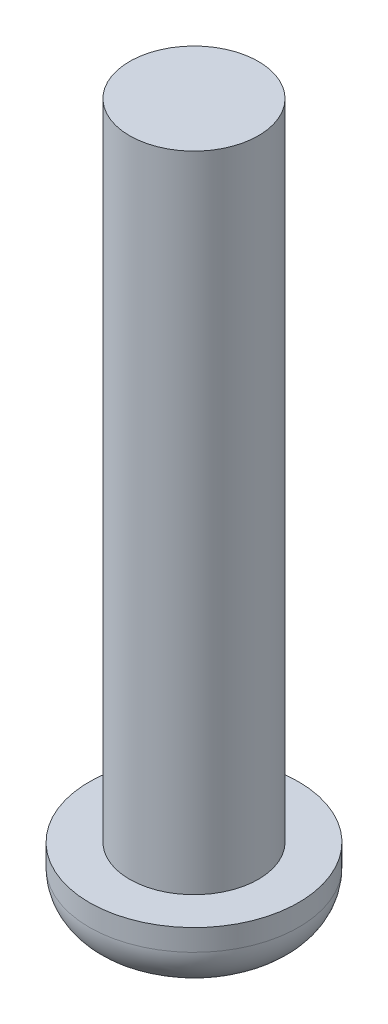
from build123d import *

# Parameters (mm, degrees)
SKETCH_1_W          = 6.5
SKETCH_1_H          = 4
SKETCH_2_R          = 4
EXTRUDE_1_DEPTH     = 40
CUT_EXTRUDE_1_DEPTH = 2
FILLET_1_R          = 2.666666667


with BuildPart() as part:
    # 草图1 → 旋转1 (revolve)
    with BuildSketch(Plane.XY):
        with Locations((33.25, 2)):
            Rectangle(SKETCH_1_W, SKETCH_1_H)
    revolve(axis=Axis((30, 4, 0), (0, -1, 0)))

    # 草图2 → 凸台-拉伸1 (add)
    with BuildSketch(Plane(origin=(0, 4, 0), x_dir=(-1, 0, 0), z_dir=(0, 1, 0))):
        with Locations((-30, 0)):
            Circle(SKETCH_2_R)
    extrude(amount=EXTRUDE_1_DEPTH)

    # 草图3 → 切除-拉伸1 (cut)
    with BuildSketch(Plane.XZ):
        Polygon((28.75, -2.165063509), (31.25, -2.165063509), (32.5, 0), (31.25, 2.165063509), (28.75, 2.165063509), (27.5, 0), align=None)
    extrude(amount=-CUT_EXTRUDE_1_DEPTH, mode=Mode.SUBTRACT)

    # 圆角1
    fillet_1_edges = [part.edges().sort_by_distance(p)[0] for p in [
        (23.5, 0, 0),
    ]]
    fillet(fillet_1_edges, radius=FILLET_1_R)


solid = part.part
